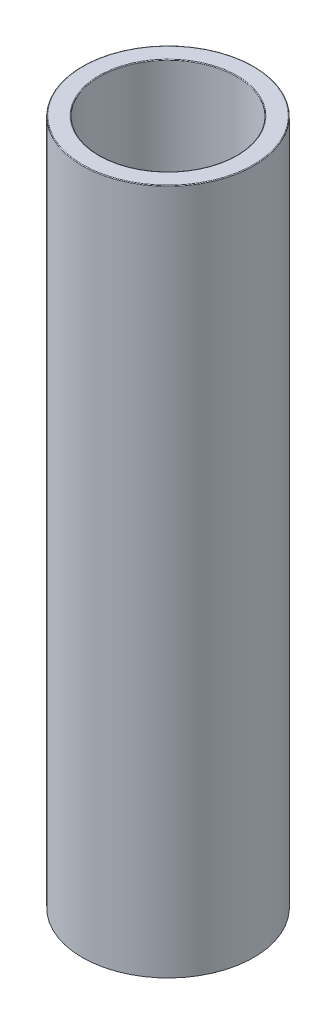
from build123d import *

# Parameters (mm, degrees)
SKETCH1_R           = 1.25
SKETCH1_R_2         = 1
BOSS_EXTRUDE1_DEPTH = 10
FILLET1_R           = 0.01


with BuildPart() as part:
    # Sketch1 → Boss-Extrude1 (new body)
    with BuildSketch(Plane(origin=(0, 0, 0), x_dir=(1, 0, 0), z_dir=(0, 1, 0))):
        Circle(SKETCH1_R)
        Circle(SKETCH1_R_2, mode=Mode.SUBTRACT)
    extrude(amount=BOSS_EXTRUDE1_DEPTH)

    # Fillet1
    fillet1_edges = [part.edges().sort_by_distance(p)[0] for p in [
        (-1.25, 10, 0),
        (-1, 0, 0),
        (-1, 10, 0),
    ]]
    fillet(fillet1_edges, radius=FILLET1_R)


solid = part.part
